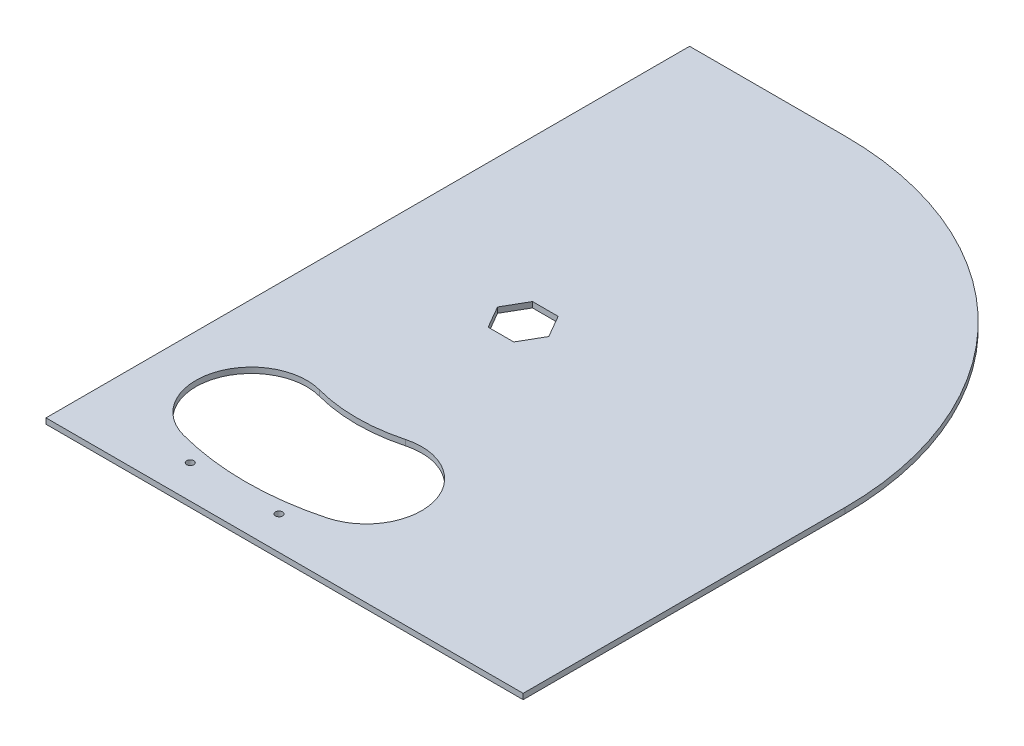
from build123d import *

# Parameters (mm, degrees)
BOSS_EXTRUDE2_DEPTH = 2.5
CUT_EXTRUDE5_DEPTH  = 3.5
CUT_EXTRUDE7_DEPTH  = 3.5
SKETCH8_R           = 1.6
CUT_EXTRUDE8_DEPTH  = 3.5


with BuildPart() as part:
    # Sketch1 → Boss-Extrude2 (new body)
    with BuildSketch(Plane(origin=(0, 0, 0), x_dir=(1, 0, 0), z_dir=(0, 1, 0))):
        with BuildLine():
            Line((0, 0), (-70, 0))
            Line((-70, 0), (-70, 290))
            Line((-70, 290), (0, 290))
            ThreePointArc((0, 290), (102.530483272, 247.530483272), (145, 145))
            Line((145, 145), (145, 0))
            Line((145, 0), (0, 0))
        make_face()
    extrude(amount=BOSS_EXTRUDE2_DEPTH)

    # Sketch6 → Cut-Extrude5 (cut, through all)
    with BuildSketch(Plane(origin=(0, 0, 0), x_dir=(1, 0, 0), z_dir=(0, 1, 0))):
        Polygon((5.773502692, 135), (11.547005384, 145), (5.773502692, 155), (-5.773502692, 155), (-11.547005384, 145), (-5.773502692, 135), align=None)
    extrude(amount=CUT_EXTRUDE5_DEPTH, mode=Mode.SUBTRACT)

    # Sketch7 → Cut-Extrude7 (cut, through all)
    with BuildSketch(Plane(origin=(0, 0, 0), x_dir=(1, 0, 0), z_dir=(0, 1, 0))):
        with BuildLine():
            ThreePointArc((-32.352380638, 24.259271714), (0, 20), (32.352380638, 24.259271714))
            ThreePointArc((32.352380638, 24.259271714), (50.030050167, 54.877893499), (19.411428383, 72.555563028))
            ThreePointArc((19.411428383, 72.555563028), (0, 70), (-19.411428383, 72.555563028))
            ThreePointArc((-19.411428383, 72.555563028), (-50.030050167, 54.877893499), (-32.352380638, 24.259271714))
        make_face()
    extrude(amount=CUT_EXTRUDE7_DEPTH, mode=Mode.SUBTRACT)

    # Sketch8 → Cut-Extrude8 (cut, through all)
    with BuildSketch(Plane(origin=(0, 0, 0), x_dir=(1, 0, 0), z_dir=(0, 1, 0))):
        with Locations((-20, 15)):
            Circle(SKETCH8_R)
        with Locations((20, 15)):
            Circle(SKETCH8_R)
    extrude(amount=CUT_EXTRUDE8_DEPTH, mode=Mode.SUBTRACT)


solid = part.part
